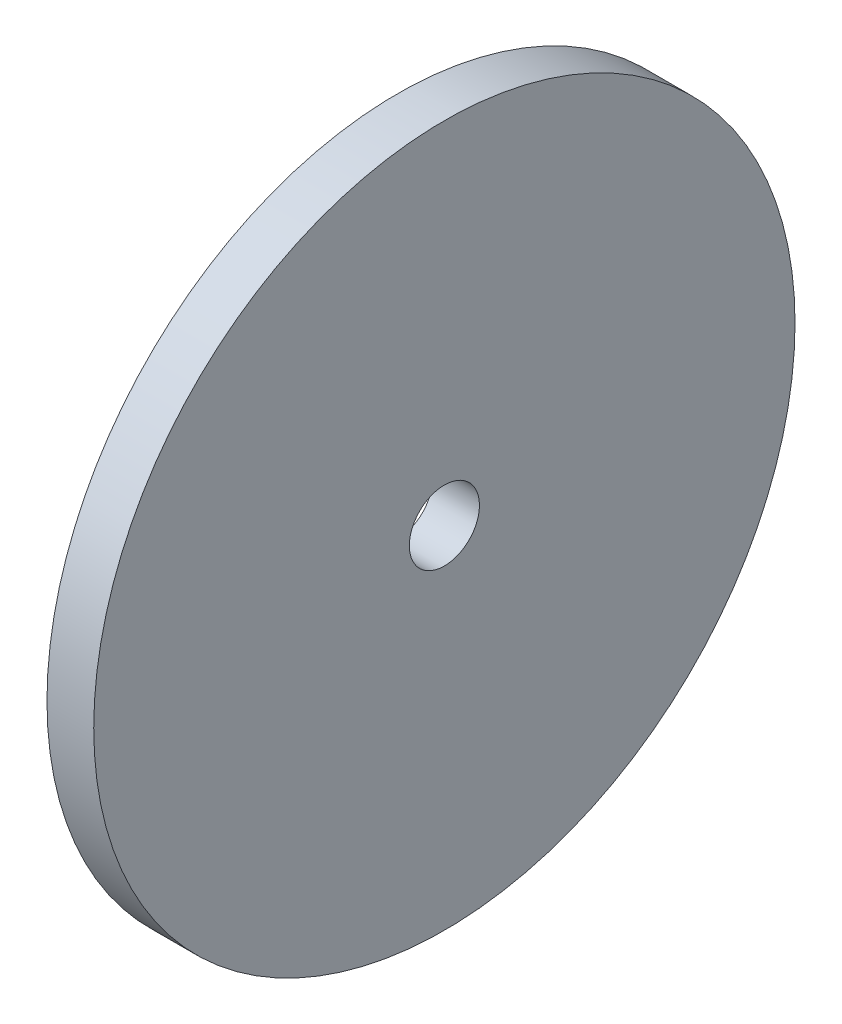
from build123d import *

# Parameters (mm, degrees)
SKETCH1_R           = 15
BOSS_EXTRUDE1_DEPTH = 2
SKETCH2_R           = 1.5
CUT_EXTRUDE1_DEPTH  = 3


with BuildPart() as part:
    # Sketch1 → Boss-Extrude1 (new body)
    with BuildSketch(Plane(origin=(0, 0, 0), x_dir=(0, 0, -1), z_dir=(1, 0, 0))):
        Circle(SKETCH1_R)
    extrude(amount=BOSS_EXTRUDE1_DEPTH)

    # Sketch2 → Cut-Extrude1 (cut, through all)
    with BuildSketch(Plane(origin=(2, 0, 0), x_dir=(0, 0, -1), z_dir=(1, 0, 0))):
        Circle(SKETCH2_R)
    extrude(amount=-CUT_EXTRUDE1_DEPTH, mode=Mode.SUBTRACT)


solid = part.part
